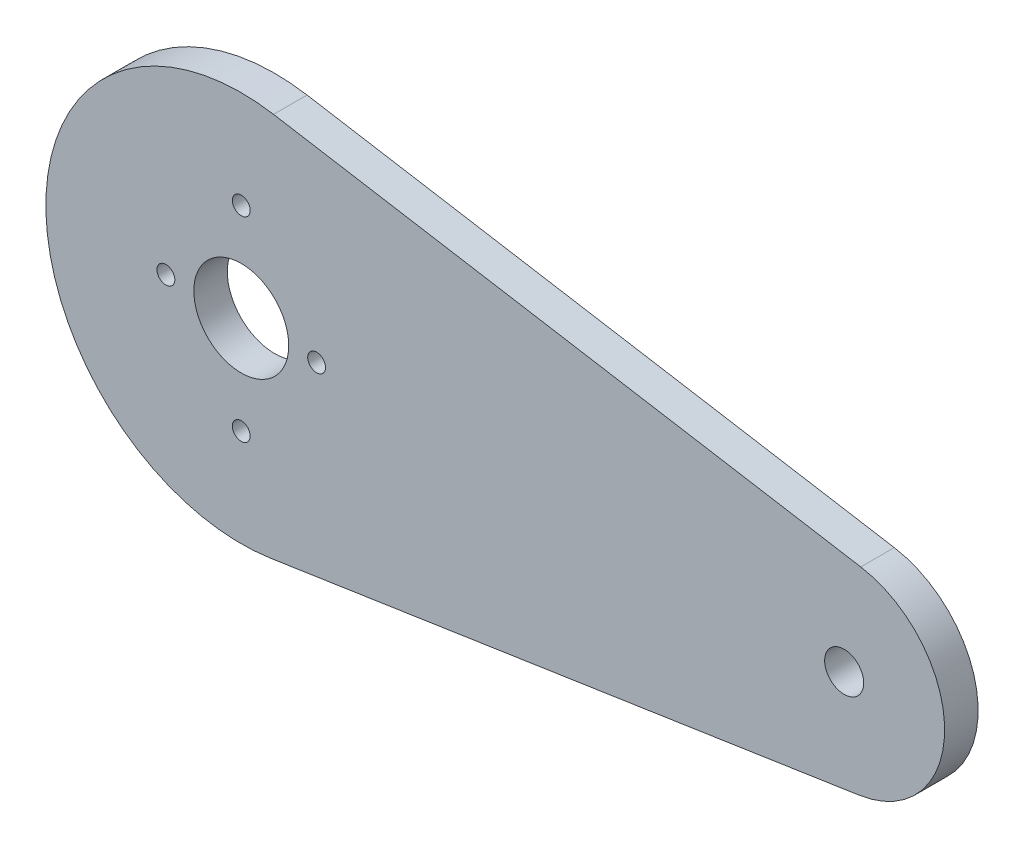
from build123d import *

# Parameters (mm, degrees)
SKETCH1_R           = 1.75
SKETCH1_R_2         = 4.25
SKETCH1_R_3         = 0.8
BOSS_EXTRUDE2_DEPTH = 3


with BuildPart() as part:
    # Sketch1 → Boss-Extrude2 (new body)
    with BuildSketch(Plane.XY):
        with BuildLine():
            Line((-17.329564893, 74.83964614), (35.264840048, 66.03177643))
            ThreePointArc((35.264840048, 66.03177643), (42.778052326, 57.084618151), (35.125066821, 48.256718465))
            Line((35.125066821, 48.256718465), (-17.601346169, 40.27703343))
            ThreePointArc((-17.601346169, 40.27703343), (-37.719458979, 57.717606069), (-17.329564893, 74.83964614))
        make_face()
        with Locations((33.778330565, 57.155386987)):
            Circle(SKETCH1_R, mode=Mode.SUBTRACT)
        with Locations((-20.22, 57.58)):
            Circle(SKETCH1_R_2, mode=Mode.SUBTRACT)
        with Locations((-13.47, 57.526921732)):
            Circle(SKETCH1_R_3, mode=Mode.SUBTRACT)
        with Locations((-26.97, 57.58)):
            Circle(SKETCH1_R_3, mode=Mode.SUBTRACT)
        with Locations((-20.22, 66.33)):
            Circle(SKETCH1_R_3, mode=Mode.SUBTRACT)
        with Locations((-20.22, 48.83)):
            Circle(SKETCH1_R_3, mode=Mode.SUBTRACT)
    extrude(amount=-BOSS_EXTRUDE2_DEPTH)


solid = part.part
